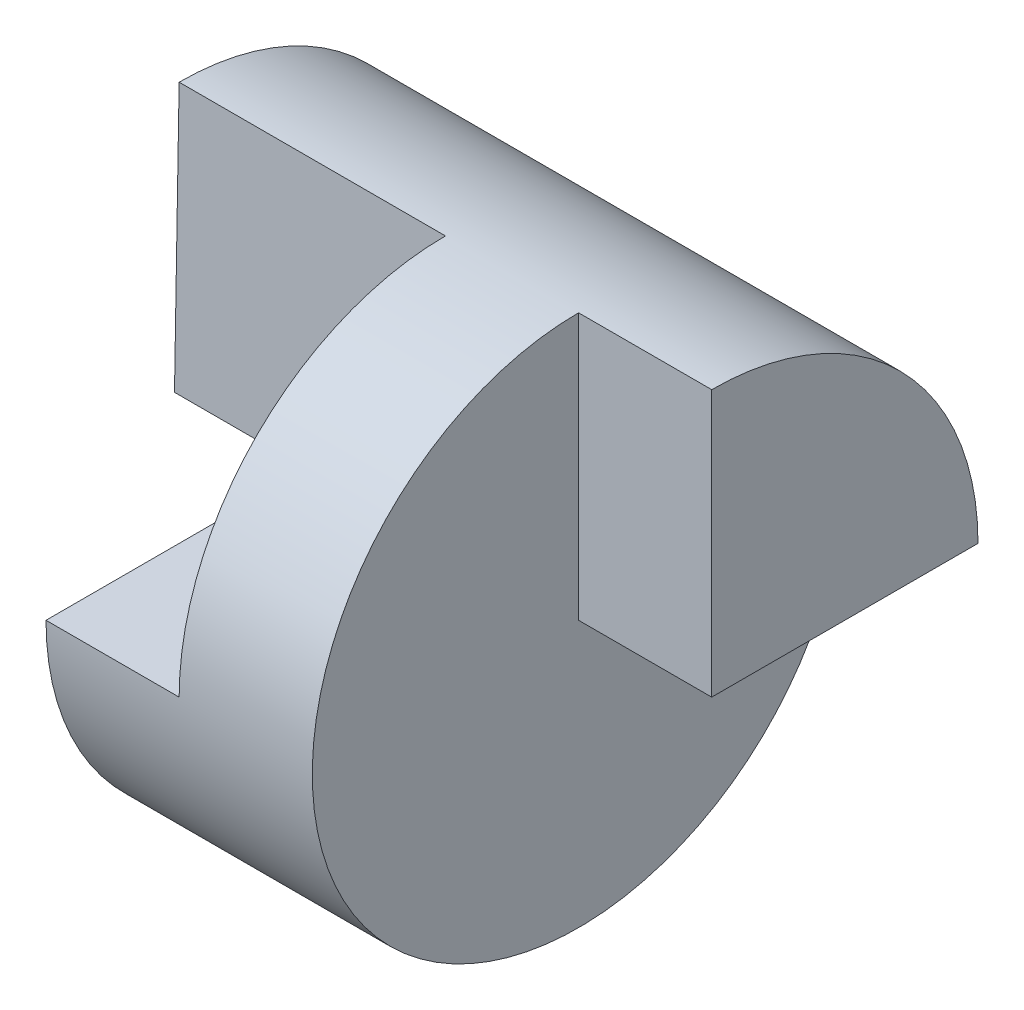
from build123d import *

# Parameters (mm, degrees)
SKETCH5_W           = 4
SKETCH5_H           = 2
SKETCH6_W           = 1
SKETCH6_H           = 2
CUT_EXTRUDE5_DEPTH  = 11
SKETCH8_W           = 0.5
SKETCH8_H           = 2
CUT_EXTRUDE7_DEPTH  = 10
SKETCH9_W           = 1.5
SKETCH9_H           = 2
CUT_EXTRUDE8_DEPTH  = 10
BOSS_EXTRUDE1_DEPTH = 4
SKETCH13_W          = 4.449870591
SKETCH13_H          = 3.198188742
CUT_EXTRUDE10_DEPTH = 1
SKETCH14_W          = 1
SKETCH14_H          = 2
CUT_EXTRUDE11_DEPTH = 10
SKETCH15_W          = 1
SKETCH15_H          = 2
CUT_EXTRUDE12_DEPTH = 5


with BuildPart() as part:
    # Sketch5 → Revolve-Thin2 (revolve)
    with BuildSketch(Plane.XY):
        with Locations((2, 1)):
            Rectangle(SKETCH5_W, SKETCH5_H)
    revolve(axis=Axis((0, 0, 0), (1, 0, 0)))

    # Sketch6 → Cut-Extrude5 (cut)
    with BuildSketch(Plane.XY):
        with Locations((3.5, 1)):
            Rectangle(SKETCH6_W, SKETCH6_H)
        with Locations((0.5, 1)):
            Rectangle(SKETCH6_W, SKETCH6_H)
    extrude(amount=-CUT_EXTRUDE5_DEPTH, mode=Mode.SUBTRACT)

    # Sketch8 → Cut-Extrude7 (cut)
    with BuildSketch(Plane(origin=(0, 0, 0), x_dir=(-1, 0, 0), z_dir=(0, 0, -1))):
        with Locations((-0.25, 1)):
            Rectangle(SKETCH8_W, SKETCH8_H)
    extrude(amount=-CUT_EXTRUDE7_DEPTH, mode=Mode.SUBTRACT)

    # Sketch9 → Cut-Extrude8 (cut)
    with BuildSketch(Plane(origin=(0, 0, 0), x_dir=(-1, 0, 0), z_dir=(0, 0, -1))):
        with Locations((-1.25, 1)):
            Rectangle(SKETCH9_W, SKETCH9_H)
    extrude(amount=-CUT_EXTRUDE8_DEPTH, mode=Mode.SUBTRACT)

    # Sketch10 → Boss-Extrude1 (add)
    with BuildSketch(Plane(origin=(4, 0, 0), x_dir=(0, 0, -1), z_dir=(1, 0, 0))):
        with BuildLine():
            Line((2, 0), (-0.034977088, 0))
            Line((-0.034977088, 0), (0, 2))
            ThreePointArc((0, 2), (1.414213562, 1.414213562), (2, 0))
        make_face()
    extrude(amount=-BOSS_EXTRUDE1_DEPTH)

    # Sketch13 → Cut-Extrude10 (cut)
    with BuildSketch(Plane.ZY):
        with Locations((-0.224935296, -1.599094371)):
            Rectangle(SKETCH13_W, SKETCH13_H)
    extrude(amount=-CUT_EXTRUDE10_DEPTH, mode=Mode.SUBTRACT)

    # Sketch14 → Cut-Extrude11 (cut)
    with BuildSketch(Plane.XY):
        with Locations((3.5, 1)):
            Rectangle(SKETCH14_W, SKETCH14_H)
    extrude(amount=CUT_EXTRUDE11_DEPTH, mode=Mode.SUBTRACT)

    # Sketch15 → Cut-Extrude12 (cut, symmetric)
    with BuildSketch(Plane.XY):
        with Locations((3.5, -1)):
            Rectangle(SKETCH15_W, SKETCH15_H)
    extrude(amount=CUT_EXTRUDE12_DEPTH, both=True, mode=Mode.SUBTRACT)


solid = part.part
